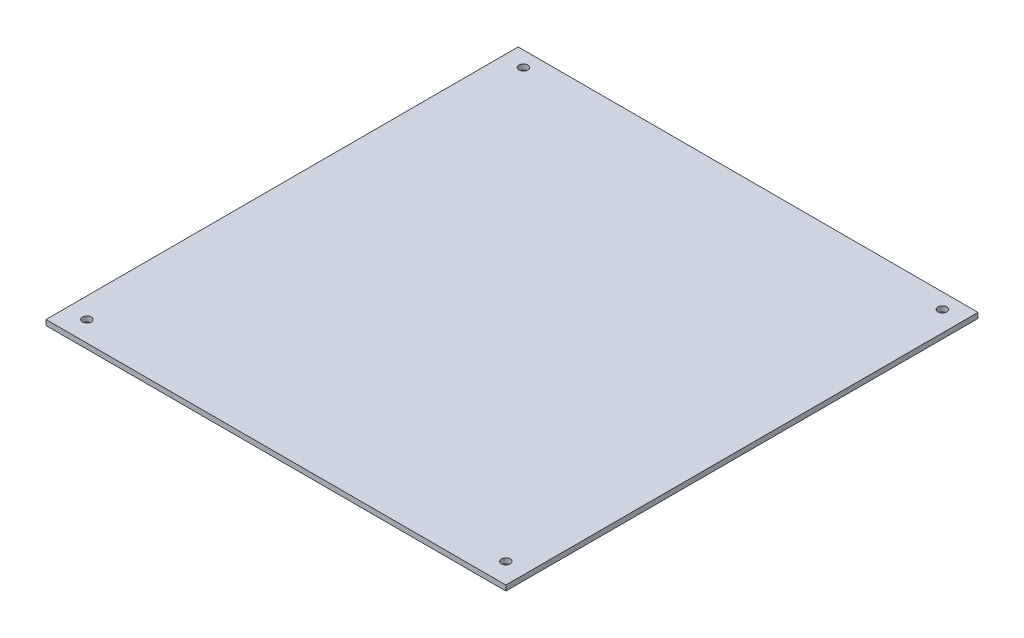
from build123d import *

# Parameters (mm, degrees)
SKETCH1_W           = 262
SKETCH1_H           = 269
SKETCH1_R           = 2.5
BOSS_EXTRUDE1_DEPTH = 3


with BuildPart() as part:
    # Sketch1 → Boss-Extrude1 (new body)
    with BuildSketch(Plane(origin=(0, 0, 0), x_dir=(1, 0, 0), z_dir=(0, 1, 0))):
        Rectangle(SKETCH1_W, SKETCH1_H)
        with Locations((119.34, -122.84)):
            Circle(SKETCH1_R, mode=Mode.SUBTRACT)
        with Locations((-119.34, -122.84)):
            Circle(SKETCH1_R, mode=Mode.SUBTRACT)
        with Locations((-119.34, 125.84)):
            Circle(SKETCH1_R, mode=Mode.SUBTRACT)
        with Locations((119.34, 125.84)):
            Circle(SKETCH1_R, mode=Mode.SUBTRACT)
    extrude(amount=BOSS_EXTRUDE1_DEPTH)


solid = part.part
